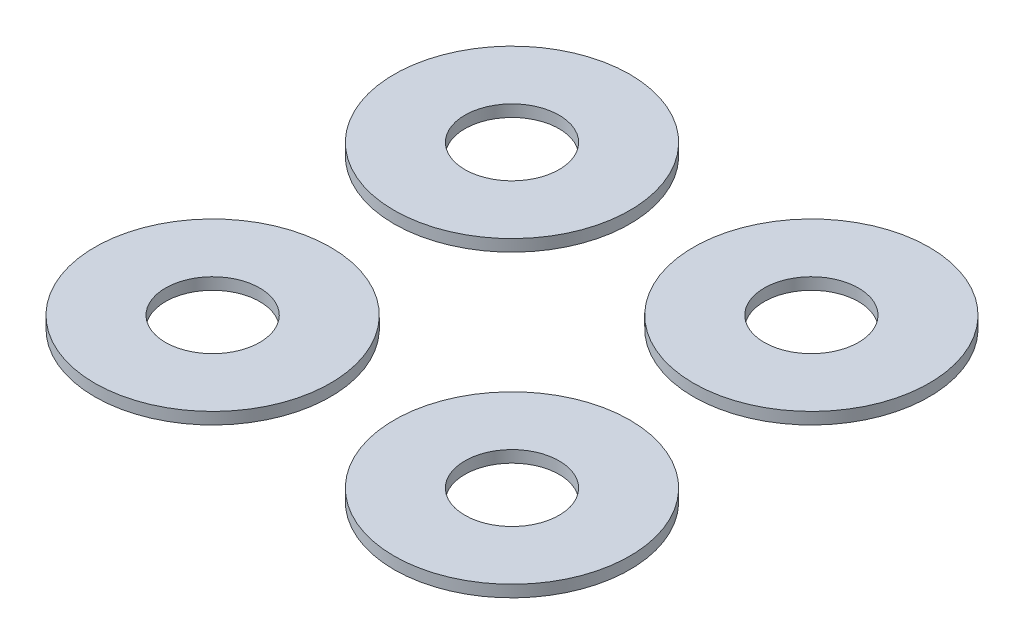
from build123d import *

# Parameters (mm, degrees)
SKETCH1_R             = 1
SKETCH1_R_2           = 0.4
BOSS_EXTRUDE1_DEPTH   = 0.1
BOSS_EXTRUDE1_2_DEPTH = 0.1
BOSS_EXTRUDE1_3_DEPTH = 0.1
BOSS_EXTRUDE1_4_DEPTH = 0.1


with BuildPart() as part:
    # Sketch1 → Boss-Extrude1 (new body)
    with BuildSketch(Plane(origin=(0, 0, 0), x_dir=(1, 0, 0), z_dir=(0, 1, 0))):
        with Locations(Location((0, 0, 0), (0, 0, 270))):  # turned: the seam where the file's is
            Circle(SKETCH1_R)
        with Locations(Location((0, 0, 0), (0, 0, 270))):  # turned: the seam where the file's is
            Circle(SKETCH1_R_2, mode=Mode.SUBTRACT)
    extrude(amount=BOSS_EXTRUDE1_DEPTH)


with BuildPart() as body_2:
    # Sketch1 → Boss-Extrude1 2 (new body)
    with BuildSketch(Plane(origin=(0, 0, 0), x_dir=(1, 0, 0), z_dir=(0, 1, 0))):
        with Locations(Location((0, 2.54, 0), (0, 0, 270))):  # turned: the seam where the file's is
            Circle(SKETCH1_R)
        with Locations(Location((0, 2.54, 0), (0, 0, 270))):  # turned: the seam where the file's is
            Circle(SKETCH1_R_2, mode=Mode.SUBTRACT)
    extrude(amount=BOSS_EXTRUDE1_2_DEPTH)


with BuildPart() as body_3:
    # Sketch1 → Boss-Extrude1 3 (new body)
    with BuildSketch(Plane(origin=(0, 0, 0), x_dir=(1, 0, 0), z_dir=(0, 1, 0))):
        with Locations(Location((2.54, 2.54, 0), (0, 0, 270))):  # turned: the seam where the file's is
            Circle(SKETCH1_R)
        with Locations(Location((2.54, 2.54, 0), (0, 0, 270))):  # turned: the seam where the file's is
            Circle(SKETCH1_R_2, mode=Mode.SUBTRACT)
    extrude(amount=BOSS_EXTRUDE1_3_DEPTH)


with BuildPart() as body_4:
    # Sketch1 → Boss-Extrude1 4 (new body)
    with BuildSketch(Plane(origin=(0, 0, 0), x_dir=(1, 0, 0), z_dir=(0, 1, 0))):
        with Locations(Location((2.54, 0, 0), (0, 0, 270))):  # turned: the seam where the file's is
            Circle(SKETCH1_R)
        with Locations(Location((2.54, 0, 0), (0, 0, 270))):  # turned: the seam where the file's is
            Circle(SKETCH1_R_2, mode=Mode.SUBTRACT)
    extrude(amount=BOSS_EXTRUDE1_4_DEPTH)


solid = Compound([part.part, body_2.part, body_3.part, body_4.part])
